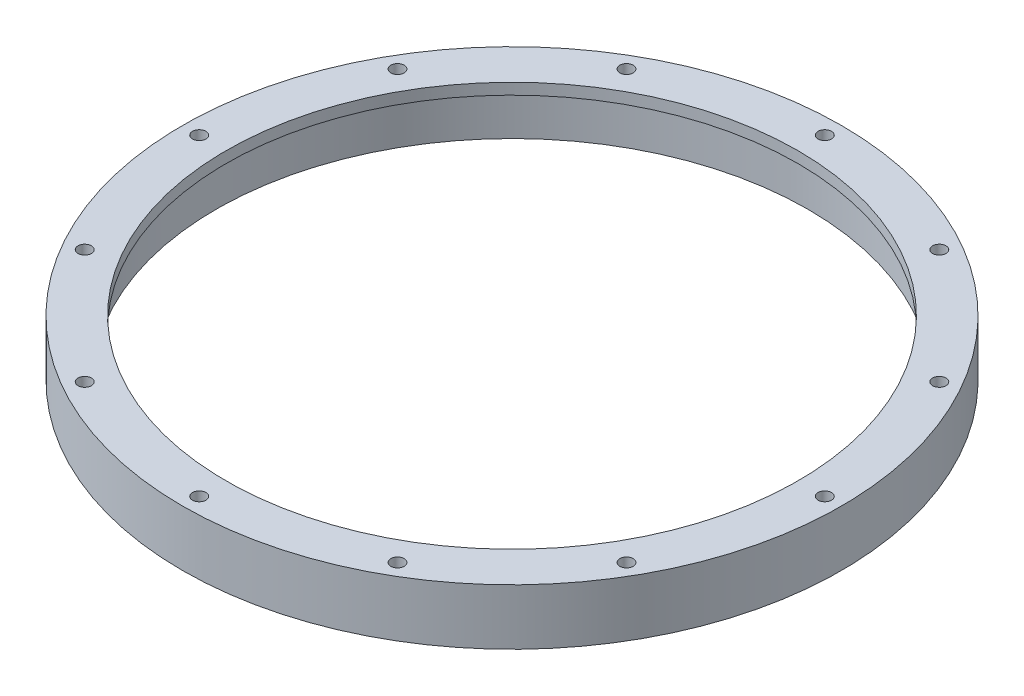
from build123d import *

# Parameters (mm, degrees)
SKETCH_2_R               = 1.2
CUT_EXTRUDE_1_DEPTH      = 10
PATTERN_CIRCULAR_1_COUNT = 12


with BuildPart() as part:
    # 草图1 → 旋转1 (revolve)
    with BuildSketch(Plane.XY):
        Polygon((-53, 0), (-59, 0), (-59, 10), (-51.2, 10), (-51.2, 8), (-53, 8), align=None)
    revolve(axis=Axis((0, 0, 0), (0, 1, 0)))

    # 草图2 → 切除-拉伸1 (cut)
    with BuildSketch(Plane.XZ):
        with Locations((0, 56)):
            Circle(SKETCH_2_R)
    cut_extrude_1 = extrude(amount=-CUT_EXTRUDE_1_DEPTH, mode=Mode.SUBTRACT)

    # 阵列(圆周)1: 切除-拉伸1 ×12 about axis
    pattern_circular_1_axis = Axis((0, 0, 0), (0, 1, 0))
    for i in range(1, PATTERN_CIRCULAR_1_COUNT):
        add(cut_extrude_1.rotate(pattern_circular_1_axis, i * 360 / PATTERN_CIRCULAR_1_COUNT), mode=Mode.SUBTRACT)


solid = part.part
